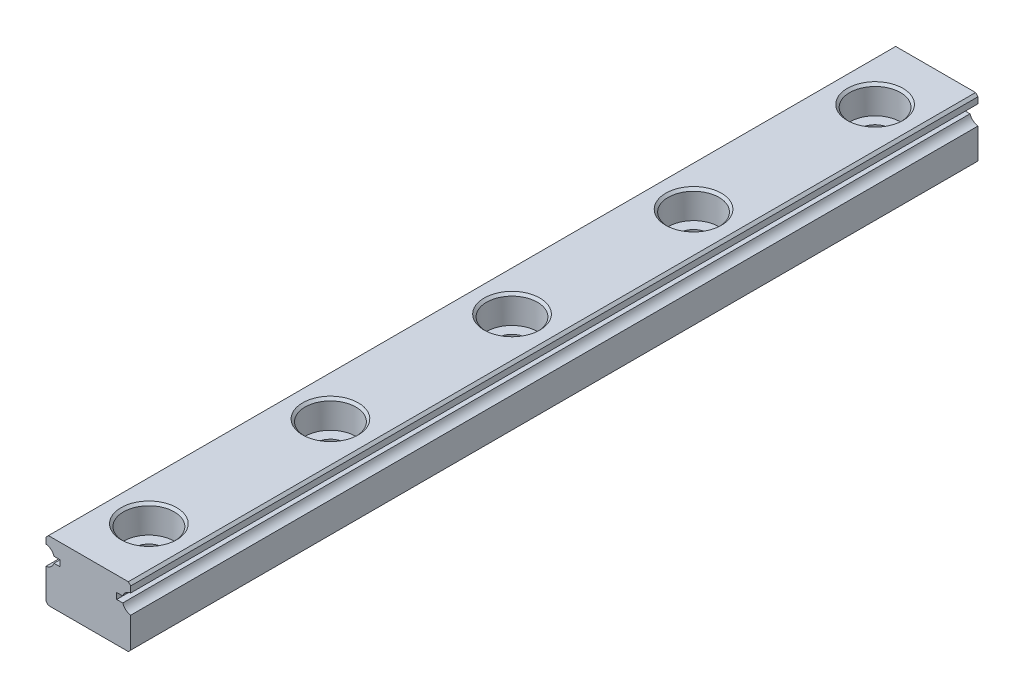
from build123d import *

# Parameters (mm, degrees)
EXTRUDE1_DEPTH             = 70
EXTRUDE2_REACH             = 72.266
SKETCH2_R                  = 1.2
SKETCH_R                   = 2.1
SKETCH_R_2                 = 1.2
EXTRUDE4_DEPTH             = 2.3
CHAMFER1_SIZE              = 0.2
LPATTERN1_COUNT            = 5
LPATTERN1_PITCH            = 15
CHAMFER1_OF_LPATTERN1_SIZE = 0.2


with BuildPart() as part:
    # Sketch1 → Extrude1 (new body)
    with BuildSketch(Plane.XY):
        with BuildLine():
            Line((-3.3, -2.5), (3.3, -2.5))
            Line((3.3, -2.5), (3.5, -2.3))
            Line((3.5, -2.3), (3.5, 0.206274607))
            ThreePointArc((3.5, 0.206274607), (3.091294745, 0.382570681), (2.840065792, 0.75))
            Line((2.840065792, 0.75), (2.340065792, 0.75))
            Line((2.340065792, 0.75), (2.340065792, 1.25))
            Line((2.340065792, 1.25), (2.840065792, 1.25))
            ThreePointArc((2.840065792, 1.25), (3.091294745, 1.617429319), (3.5, 1.793725393))
            Line((3.5, 1.793725393), (3.5, 2.3))
            Line((3.5, 2.3), (3.3, 2.5))
            Line((3.3, 2.5), (-3.3, 2.5))
            Line((-3.3, 2.5), (-3.5, 2.3))
            Line((-3.5, 2.3), (-3.5, 1.793725393))
            ThreePointArc((-3.5, 1.793725393), (-3.091294745, 1.617429319), (-2.840065792, 1.25))
            Line((-2.840065792, 1.25), (-2.340065792, 1.25))
            Line((-2.340065792, 1.25), (-2.340065792, 0.75))
            Line((-2.340065792, 0.75), (-2.840065792, 0.75))
            ThreePointArc((-2.840065792, 0.75), (-3.091294745, 0.382570681), (-3.5, 0.206274607))
            Line((-3.5, 0.206274607), (-3.5, -2.3))
            Line((-3.5, -2.3), (-3.3, -2.5))
        make_face()
    extrude(amount=EXTRUDE1_DEPTH)

    # Sketch2 → Extrude2 (cut, up to next)
    with BuildSketch(Plane(origin=(0, 2.5, 0), x_dir=(1, 0, 0), z_dir=(0, 1, 0)), mode=Mode.PRIVATE) as extrude2_sk1:
        with Locations((0, -5)):
            Circle(SKETCH2_R)
    extrude2_tool1 = extrude(extrude2_sk1.sketch, amount=-EXTRUDE2_REACH, mode=Mode.PRIVATE) & part.part
    extrude2 = extrude2_tool1.solids().sort_by_distance((0, 2.5, 5))[0]
    add(extrude2, mode=Mode.SUBTRACT)

    # Sketch → Extrude4 (cut)
    with BuildSketch(Plane(origin=(0, 2.5, 0), x_dir=(1, 0, 0), z_dir=(0, 1, 0))):
        with Locations((0, -5)):
            Circle(SKETCH_R)
        with Locations((0, -5)):
            Circle(SKETCH_R_2, mode=Mode.SUBTRACT)
    extrude4 = extrude(amount=-EXTRUDE4_DEPTH, mode=Mode.SUBTRACT)

    # Chamfer1
    chamfer1_edges = [part.edges().sort_by_distance(p)[0] for p in [
        (-1.2, -2.5, 5),
        (-2.1, 2.5, 5),
    ]]
    chamfer(chamfer1_edges, length=CHAMFER1_SIZE)

    # LPattern1: Extrude2, Extrude4 ×5
    with Locations(*[(0, 0, i * LPATTERN1_PITCH) for i in range(1, LPATTERN1_COUNT)]):
        add(extrude2, mode=Mode.SUBTRACT)
        add(extrude4, mode=Mode.SUBTRACT)

    # Chamfer1 of LPattern1
    chamfer1_of_lpattern1_edges = [part.edges().sort_by_distance(p)[0] for p in [
        (-1.2, -2.5, 20),
        (-2.1, 2.5, 20),
        (-1.2, -2.5, 35),
        (-2.1, 2.5, 35),
        (-1.2, -2.5, 50),
        (-2.1, 2.5, 50),
        (-1.2, -2.5, 65),
        (-2.1, 2.5, 65),
    ]]
    chamfer(chamfer1_of_lpattern1_edges, length=CHAMFER1_OF_LPATTERN1_SIZE)


solid = part.part
